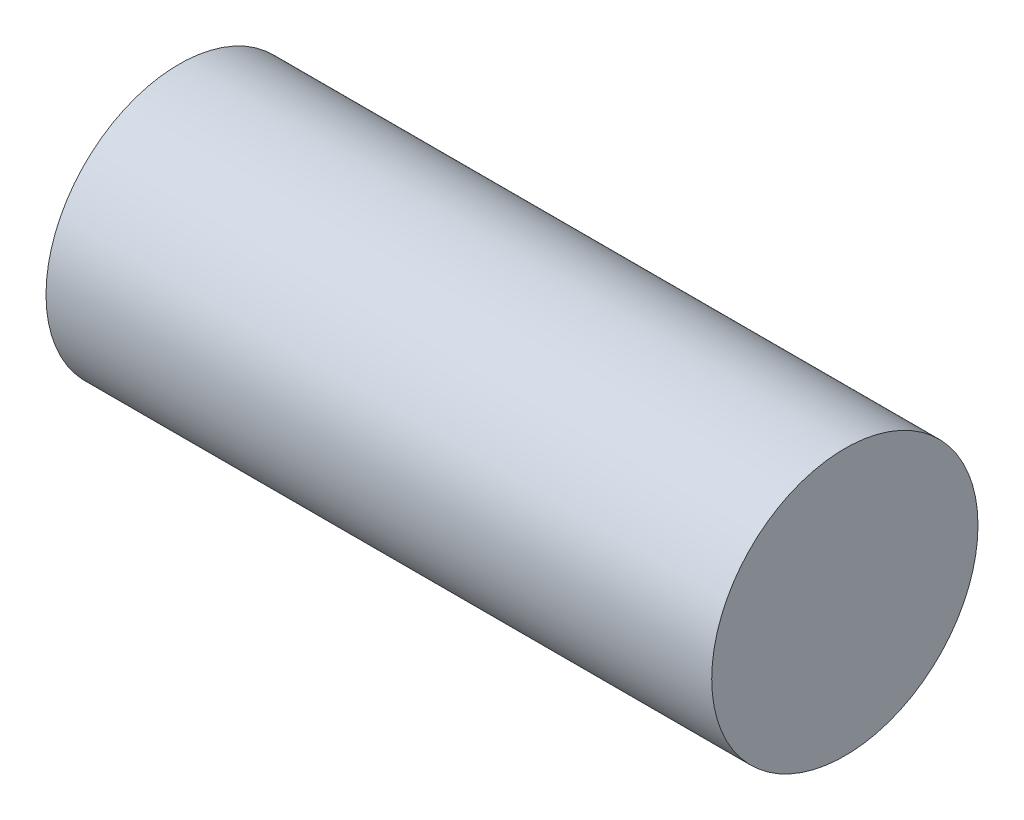
from build123d import *

# Parameters (mm, degrees)
SCHIZZO1_W = 40
SCHIZZO1_H = 8


with BuildPart() as part:
    # Schizzo1 → Rivoluzione1 (revolve)
    with BuildSketch(Plane.XY):
        with Locations((20, 4)):
            Rectangle(SCHIZZO1_W, SCHIZZO1_H)
    revolve(axis=Axis((0, 8, 0), (1, 0, 0)))


solid = part.part
